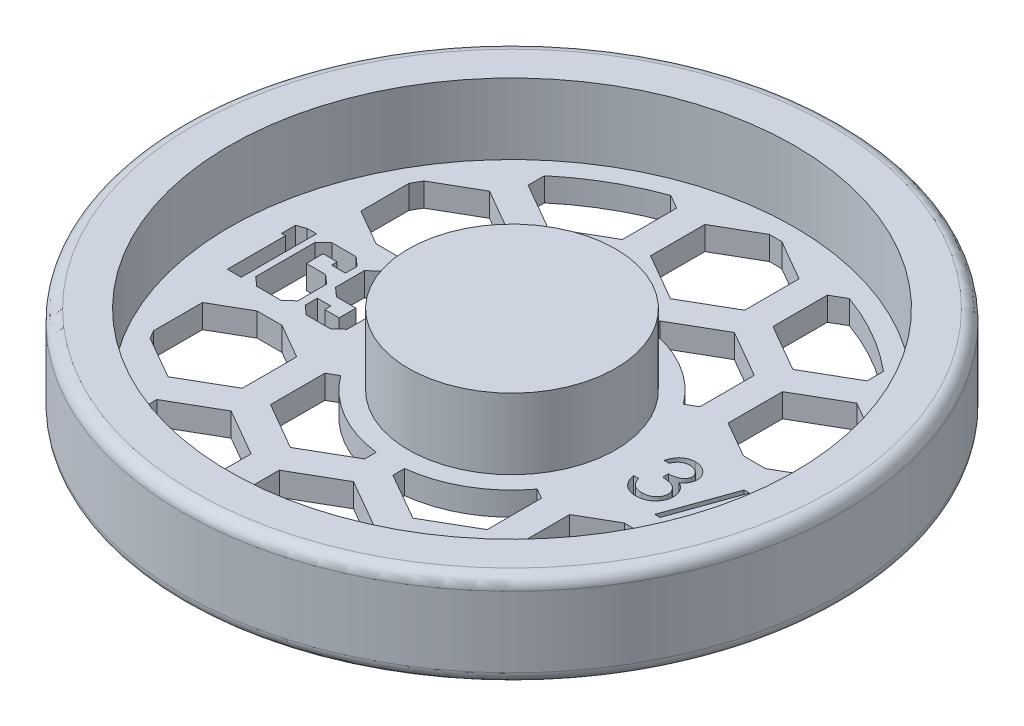
from build123d import *

# Parameters (mm, degrees)
SKETCH2_W               = 1.935420596
SKETCH2_H               = 2.263100716
SKETCH2_W_2             = 1.881765372
CUT_EXTRUDE1_DEPTH      = 64.579325537
CUT_EXTRUDE1_DEPTH_BACK = 64.579325537
CUT_EXTRUDE4_DEPTH      = 64.579325537
CUT_EXTRUDE4_DEPTH_BACK = 64.579325537


with BuildPart() as part:
    # Sketch1 → Revolve1 (revolve)
    with BuildSketch(Plane.XY, mode=Mode.PRIVATE) as revolve1_sk:
        with BuildLine():
            Line((0, 0), (0, 12.7))
            Line((0, 12.7), (13.97, 12.7))
            Line((13.97, 12.7), (13.97, 3.175))
            Line((13.97, 3.175), (38.1, 3.175))
            Line((38.1, 3.175), (38.1, 12.7))
            Line((38.1, 12.7), (42.8625, 12.7))
            ThreePointArc((42.8625, 12.7), (43.985032015, 12.235032015), (44.45, 11.1125))
            Line((44.45, 11.1125), (44.45, 1.5875))
            ThreePointArc((44.45, 1.5875), (43.985032015, 0.464967985), (42.8625, 0))
            Line((42.8625, 0), (0, 0))
        make_face()
    revolve(revolve1_sk.sketch.rotate(Axis((0, 0, 0), (0, 1, 0)), 90), axis=Axis((0, 0, 0), (0, 1, 0)))

    # Sketch2 → Cut-Extrude1 (cut, two sides)
    with BuildSketch(Plane(origin=(0, 3.175, 0), x_dir=(1, 0, 0), z_dir=(0, 1, 0))) as cut_extrude1_sk:
        Polygon((-18.235829876, -4.018393059), (-19.437323651, -5.08), (-22.671967182, -5.08), (-23.875377216, -4.018393059), (-23.875377216, -2.383824972), (-22.045350811, -2.383824972), (-22.045350811, -3.203983402), (-20.109930215, -3.203983402), (-20.109930215, -0.940882686), (-22.729454923, -0.940882686), (-23.927116183, 0.120724255), (-23.927116183, 4.012644285), (-22.729454923, 5.08), (-19.450737458, 5.08), (-18.235829876, 4.006895511), align=None)
        with Locations((-21.077640513, 2.072433044)):
            Rectangle(SKETCH2_W, SKETCH2_H, mode=Mode.SUBTRACT)
        Polygon((-24.883328932, -4.018393059), (-26.086738966, -5.08), (-29.346293851, -5.08), (-30.549703885, -4.018393059), (-30.549703885, 4.012644285), (-29.359707657, 5.08), (-26.105901547, 5.08), (-24.902491513, 4.012644285), (-24.902491513, 2.441312712), (-26.784256884, 2.441312712), (-26.784256884, 3.203983402), (-28.673687288, 3.203983402), (-28.673687288, 0.940882686), (-26.086738966, 0.940882686), (-24.883328932, -0.113059223), align=None)
        with Locations((-27.732804602, -2.072433044)):
            Rectangle(SKETCH2_W_2, SKETCH2_H, mode=Mode.SUBTRACT)
        Polygon((-31.448428895, -5.08), (-33.324445492, -5.08), (-33.324445492, 2.770909091), (-33.860997737, 2.770909091), (-33.860997737, 4.646925688), (-32.703577895, 5.08), (-31.448428895, 5.08), align=None)
        with BuildLine():
            Line((19.147692308, 2.051538462), (18.463846154, 2.051538462))
            add(Edge.make_bspline(
                [(18.463846154, 2.051538462), (18.482372661, 2.128244612), (18.518590468, 2.278198863), (18.594132042, 2.492445528), (18.676426421, 2.695188738), (18.775244986, 2.88263219), (18.883032616, 3.058542943), (19.006526084, 3.218931152), (19.14002788, 3.367875951), (19.287692484, 3.500057342), (19.442549742, 3.619751713), (19.606781685, 3.721805409), (19.7770841, 3.80959685), (19.95463692, 3.881922041), (20.139968757, 3.936406181), (20.331404108, 3.975936141), (20.529444643, 4.001607081), (20.663877969, 4.004112456), (20.732139423, 4.005384615)],
                knots=[0, 0, 0, 0, 1.162005537, 2.271625781, 3.343758855, 4.383309926, 5.390229558, 6.379919256, 7.361854164, 8.333198761, 9.295911338, 10.242430842, 11.177959212, 12.116337295, 13.062827104, 14.020064771, 14.994644689, 16, 16, 16, 16], degree=3))
            add(Edge.make_bspline(
                [(20.732139423, 4.005384615), (20.831597279, 4.002381834), (21.028343525, 3.996441771), (21.317387645, 3.942199484), (21.596120319, 3.856365338), (21.861490625, 3.737768252), (22.107983327, 3.591491873), (22.327300396, 3.417397218), (22.516469097, 3.21884331), (22.67517057, 2.999534127), (22.799430997, 2.765152704), (22.891059044, 2.523924933), (22.946841104, 2.276423041), (22.954070431, 2.109311479), (22.957692308, 2.025588942)],
                knots=[0, 0, 0, 0, 1.083050992, 2.142477498, 3.193116406, 4.255571735, 5.30263384, 6.308962982, 7.297363603, 8.282367274, 9.249857812, 10.179914175, 11.08814088, 12, 12, 12, 12], degree=3))
            add(Edge.make_bspline(
                [(22.957692308, 2.025588942), (22.955159004, 1.945019864), (22.950201721, 1.787358679), (22.908109482, 1.557187877), (22.83727339, 1.340253879), (22.739150078, 1.135643463), (22.612132189, 0.944653954), (22.458267632, 0.766855643), (22.276470408, 0.601459933), (22.13870312, 0.506711824), (22.067776442, 0.457932692)],
                knots=[0, 0, 0, 0, 1.024540389, 2.004866551, 2.965041327, 3.920577974, 4.882998113, 5.874504559, 6.905732034, 8, 8, 8, 8], degree=3))
            add(Edge.make_bspline(
                [(22.067776442, 0.457932692), (22.148835291, 0.418791645), (22.309436314, 0.341241908), (22.528349181, 0.189155945), (22.727074156, 0.013555554), (22.837898824, -0.123479593), (22.893581731, -0.192331731)],
                knots=[0, 0, 0, 0, 1.015518401, 2.012035669, 3.001164323, 4, 4, 4, 4], degree=3))
            add(Edge.make_bspline(
                [(22.893581731, -0.192331731), (22.930247739, -0.24253175), (23.002979324, -0.342109728), (23.092754972, -0.502209033), (23.174199958, -0.664082847), (23.23766415, -0.832069896), (23.286810683, -1.004223143), (23.32194113, -1.180838188), (23.343765117, -1.362059254), (23.346890518, -1.484659568), (23.348461538, -1.546286058)],
                knots=[0, 0, 0, 0, 1.025084078, 2.033381695, 3.024893161, 4.013698104, 4.991890475, 5.976764909, 6.982997093, 8, 8, 8, 8], degree=3))
            add(Edge.make_bspline(
                [(23.348461538, -1.546286058), (23.344554626, -1.652987222), (23.336759188, -1.865887414), (23.267081746, -2.180429522), (23.159066633, -2.487897615), (23.005671818, -2.781974837), (22.818725985, -3.057122981), (22.596314896, -3.303306259), (22.34096563, -3.514921506), (22.056183046, -3.691727774), (21.747644612, -3.833063365), (21.417642894, -3.931159855), (21.070932777, -3.995050288), (20.833172889, -4.001901471), (20.712295673, -4.005384615)],
                knots=[0, 0, 0, 0, 0.955779014, 1.907060117, 2.875433937, 3.871313158, 4.872415639, 5.851225146, 6.836215519, 7.83643374, 8.849228613, 9.86973379, 10.916971861, 12, 12, 12, 12], degree=3))
            add(Edge.make_bspline(
                [(20.712295673, -4.005384615), (20.630828511, -4.003494391), (20.470528301, -3.99977506), (20.234866742, -3.974349077), (20.009920642, -3.927910608), (19.795385861, -3.865419412), (19.59107181, -3.786189391), (19.397601958, -3.687524111), (19.213786019, -3.571457355), (19.041358588, -3.436619087), (18.88034022, -3.285783713), (18.735010004, -3.116273525), (18.602944969, -2.931222035), (18.487681281, -2.728479838), (18.38396883, -2.510667021), (18.29866629, -2.274994576), (18.223586281, -2.023569362), (18.188679138, -1.848357825), (18.170769231, -1.758461538)],
                knots=[0, 0, 0, 0, 1.048658725, 2.063410685, 3.046034179, 4.001477787, 4.936774919, 5.862367409, 6.792675028, 7.730719943, 8.675894397, 9.627829632, 10.600096036, 11.597688215, 12.626045268, 13.701542398, 14.82072376, 16, 16, 16, 16], degree=3))
            Line((18.170769231, -1.758461538), (18.854615385, -1.758461538))
            add(Edge.make_bspline(
                [(18.854615385, -1.758461538), (18.872431579, -1.81713339), (18.907085625, -1.931255238), (18.966073782, -2.095499561), (19.03327842, -2.246066522), (19.105373545, -2.384060634), (19.181091191, -2.510840893), (19.265814542, -2.623054905), (19.353268509, -2.725631431), (19.419190987, -2.783422843), (19.451454327, -2.811706731)],
                knots=[0, 0, 0, 0, 1.198163088, 2.33053128, 3.407730985, 4.417276592, 5.372219308, 6.28897303, 7.162600585, 8, 8, 8, 8], degree=3))
            add(Edge.make_bspline(
                [(19.451454327, -2.811706731), (19.494118874, -2.844599732), (19.579316271, -2.910284201), (19.71814882, -2.994107747), (19.864158658, -3.066739465), (20.020509463, -3.122221111), (20.183827334, -3.169198761), (20.356752055, -3.199941148), (20.537758008, -3.221033681), (20.661349539, -3.222894989), (20.724507212, -3.223846154)],
                knots=[0, 0, 0, 0, 0.946170439, 1.889420265, 2.845303464, 3.807233317, 4.801018734, 5.828864929, 6.890507805, 8, 8, 8, 8], degree=3))
            add(Edge.make_bspline(
                [(20.724507212, -3.223846154), (20.795816266, -3.22250524), (20.935254966, -3.219883199), (21.138719545, -3.195769803), (21.33228376, -3.160651589), (21.513798529, -3.106412466), (21.68564152, -3.039398155), (21.845403854, -2.955255055), (21.995182805, -2.856533119), (22.133059968, -2.744325007), (22.257038473, -2.621487352), (22.366199356, -2.493007466), (22.458999333, -2.35942706), (22.533857295, -2.220006923), (22.592967922, -2.075324396), (22.63320849, -1.924973459), (22.661188074, -1.770184553), (22.663466698, -1.664965484), (22.664615385, -1.611923077)],
                knots=[0, 0, 0, 0, 1.217147791, 2.380027433, 3.494444702, 4.572153297, 5.609568379, 6.639424714, 7.649109417, 8.668170816, 9.669597737, 10.625200337, 11.543417969, 12.441394052, 13.322311151, 14.205496177, 15.095365482, 16, 16, 16, 16], degree=3))
            add(Edge.make_bspline(
                [(22.664615385, -1.611923077), (22.6612837, -1.540923533), (22.654636908, -1.39927773), (22.6038908, -1.190886897), (22.520421616, -0.990103354), (22.403568891, -0.800352748), (22.261323676, -0.624492071), (22.095066365, -0.467582157), (21.903416336, -0.338107273), (21.727024507, -0.248651399), (21.570781509, -0.187610681), (21.437071444, -0.146952615), (21.287378496, -0.112524028), (21.123512902, -0.080493311), (20.944239956, -0.053232547), (20.749754831, -0.030499223), (20.540018116, -0.012309105), (20.394821921, -0.004185977), (20.32, 0)],
                knots=[0, 0, 0, 0, 1.07054697, 2.135767047, 3.216561865, 4.33974944, 5.486079747, 6.621378074, 7.775625952, 8.963672916, 9.598146892, 10.304877434, 11.070270905, 11.915000392, 12.823868403, 13.805723172, 14.86925407, 16, 16, 16, 16], degree=3))
            Line((20.32, 0), (20.32, 0.781538462))
            add(Edge.make_bspline(
                [(20.32, 0.781538462), (20.414272824, 0.783138234), (20.598930127, 0.786271796), (20.868665727, 0.824171521), (21.126599053, 0.876598489), (21.367013845, 0.956902822), (21.586140473, 1.050172268), (21.776247721, 1.15870765), (21.934672195, 1.279353475), (22.060644014, 1.413971899), (22.155413363, 1.558349231), (22.224704848, 1.708826069), (22.265635844, 1.86672131), (22.271099747, 1.974478273), (22.273846154, 2.028641827)],
                knots=[0, 0, 0, 0, 1.321986639, 2.589447074, 3.816329219, 5.01088745, 6.139805852, 7.153945165, 8.075214402, 8.924034688, 9.728124013, 10.488707548, 11.240355623, 12, 12, 12, 12], degree=3))
            add(Edge.make_bspline(
                [(22.273846154, 2.028641827), (22.272943922, 2.068435089), (22.271148974, 2.147601897), (22.248512615, 2.263262761), (22.214496846, 2.375387678), (22.167732407, 2.483499825), (22.105139117, 2.586849392), (22.030232369, 2.686317495), (21.941038963, 2.781336237), (21.838832018, 2.869903104), (21.729078317, 2.954309272), (21.608791664, 3.025966962), (21.481598896, 3.087242783), (21.347359196, 3.137773184), (21.205636928, 3.175784549), (21.057097965, 3.203076866), (20.901459065, 3.22014056), (20.795276037, 3.222597283), (20.741298077, 3.223846154)],
                knots=[0, 0, 0, 0, 0.884392785, 1.759457502, 2.611959086, 3.489218968, 4.37281399, 5.2945488, 6.255912374, 7.266815255, 8.301784654, 9.332968512, 10.37626691, 11.440494194, 12.520033166, 13.637162961, 14.798855837, 16, 16, 16, 16], degree=3))
            add(Edge.make_bspline(
                [(20.741298077, 3.223846154), (20.654535303, 3.22081696), (20.485067425, 3.21490024), (20.24075952, 3.163077679), (20.013641427, 3.080393966), (19.840038959, 2.981697507), (19.711843183, 2.884269419), (19.620235678, 2.799181481), (19.530275023, 2.704622019), (19.447879578, 2.594766928), (19.364551664, 2.477055802), (19.288690075, 2.345504815), (19.214972688, 2.203545534), (19.170553423, 2.103188752), (19.147692308, 2.051538462)],
                knots=[0, 0, 0, 0, 1.472543308, 2.876219568, 4.221790263, 5.565193594, 6.249813518, 6.953379497, 7.687249741, 8.463570142, 9.283606569, 10.136032583, 11.040678096, 12, 12, 12, 12], degree=3))
        make_face()
        Polygon((28.037692308, 4.005384615), (24.850480769, -4.884615385), (24.13, -4.884615385), (27.317211538, 4.005384615), align=None)
        with BuildLine():
            add(Edge.make_bspline(
                [(32.328521635, 0.435036058), (32.390893614, 0.402513994), (32.512539805, 0.339085107), (32.685790756, 0.236953534), (32.844123473, 0.12931349), (32.991930924, 0.021249134), (33.126616277, -0.091378062), (33.246673541, -0.209015962), (33.355068302, -0.32872822), (33.449614615, -0.452541986), (33.532774585, -0.580128325), (33.604646719, -0.711822114), (33.666079601, -0.847334743), (33.714766913, -0.988145442), (33.754873786, -1.132185783), (33.782470389, -1.281315675), (33.797311792, -1.43455244), (33.800117723, -1.538115428), (33.801538462, -1.590552885)],
                knots=[0, 0, 0, 0, 1.272397273, 2.481599622, 3.635517121, 4.734568067, 5.792894095, 6.808321871, 7.773003508, 8.711915296, 9.623354172, 10.525449501, 11.423591555, 12.311487226, 13.218079475, 14.126165749, 15.051214107, 16, 16, 16, 16], degree=3))
            add(Edge.make_bspline(
                [(33.801538462, -1.590552885), (33.799858969, -1.663917663), (33.796534623, -1.809134086), (33.767578657, -2.023465334), (33.724225258, -2.231625842), (33.660915006, -2.433569974), (33.578807567, -2.628183409), (33.477620855, -2.815632739), (33.363078746, -2.998990206), (33.271089585, -3.111808446), (33.224543269, -3.168894231)],
                knots=[0, 0, 0, 0, 1.025265484, 2.029385089, 3.018602448, 3.995076438, 4.983346944, 5.966715145, 6.97116228, 8, 8, 8, 8], degree=3))
            add(Edge.make_bspline(
                [(33.224543269, -3.168894231), (33.163939288, -3.235501248), (33.043480226, -3.3678922), (32.837124252, -3.539779392), (32.610653751, -3.684231502), (32.364945038, -3.801953741), (32.100654914, -3.893580668), (31.817839693, -3.95942295), (31.515948023, -3.997136353), (31.308454397, -4.002587896), (31.202007212, -4.005384615)],
                knots=[0, 0, 0, 0, 0.954267603, 1.896743057, 2.838368354, 3.796610408, 4.779680527, 5.799409237, 6.871065594, 8, 8, 8, 8], degree=3))
            add(Edge.make_bspline(
                [(31.202007212, -4.005384615), (31.099652348, -4.002875506), (30.900480181, -3.997993035), (30.610576459, -3.964912587), (30.340342804, -3.906939917), (30.088207959, -3.827594796), (29.855691946, -3.724375956), (29.643457309, -3.59590622), (29.448441975, -3.447356623), (29.276564224, -3.27446083), (29.123971669, -3.089277691), (28.989929222, -2.898229901), (28.878515943, -2.701300019), (28.784186667, -2.501424443), (28.711975143, -2.295801673), (28.661961359, -2.085489644), (28.630198338, -1.870855705), (28.62597221, -1.726006791), (28.623846154, -1.653137019)],
                knots=[0, 0, 0, 0, 1.256902934, 2.445805442, 3.576955095, 4.645999104, 5.686449165, 6.692658513, 7.68621702, 8.689161843, 9.678783111, 10.630372946, 11.551080876, 12.453998257, 13.34127905, 14.221779781, 15.105423033, 16, 16, 16, 16], degree=3))
            add(Edge.make_bspline(
                [(28.623846154, -1.653137019), (28.625104283, -1.59966815), (28.627590791, -1.493994791), (28.644800775, -1.337873339), (28.672468911, -1.185917183), (28.710045214, -1.03756505), (28.76097082, -0.893896976), (28.822457979, -0.754232231), (28.894155544, -0.618413135), (28.97706368, -0.485696943), (29.073515516, -0.357943262), (29.182728947, -0.232983982), (29.306886764, -0.112758089), (29.444607724, 0.004203305), (29.59431795, 0.119974997), (29.75990606, 0.228300326), (29.93698238, 0.336848238), (30.062833006, 0.40174522), (30.127391827, 0.435036058)],
                knots=[0, 0, 0, 0, 0.941657376, 1.861047343, 2.762797495, 3.66048619, 4.553285746, 5.444104102, 6.34607688, 7.256116206, 8.197091036, 9.162375105, 10.176350973, 11.237807142, 12.343728897, 13.50695164, 14.721116704, 16, 16, 16, 16], degree=3))
            add(Edge.make_bspline(
                [(30.127391827, 0.435036058), (30.039018605, 0.483226611), (29.867903313, 0.576537011), (29.641329273, 0.747980057), (29.446713115, 0.933663814), (29.289404273, 1.137509253), (29.165585308, 1.353148448), (29.080636232, 1.57923222), (29.023167315, 1.811568445), (29.017474463, 1.97029565), (29.014615385, 2.050012019)],
                knots=[0, 0, 0, 0, 1.166880483, 2.259407225, 3.286803203, 4.280235371, 5.237608625, 6.161067461, 7.076446754, 8, 8, 8, 8], degree=3))
            add(Edge.make_bspline(
                [(29.014615385, 2.050012019), (29.018175937, 2.131214132), (29.025333267, 2.29444454), (29.083208953, 2.537427014), (29.177522927, 2.776077936), (29.305802354, 3.009240602), (29.465576808, 3.229023641), (29.657266716, 3.426144215), (29.876294465, 3.598816643), (30.121566736, 3.743762482), (30.38551534, 3.861728048), (30.664006145, 3.943106214), (30.95218691, 3.996307131), (31.148342516, 4.002330533), (31.247800481, 4.005384615)],
                knots=[0, 0, 0, 0, 0.888701115, 1.786444228, 2.72001202, 3.692817113, 4.693886446, 5.687152267, 6.695133018, 7.739871481, 8.800368666, 9.853104506, 10.91144658, 12, 12, 12, 12], degree=3))
            add(Edge.make_bspline(
                [(31.247800481, 4.005384615), (31.344691644, 4.00223572), (31.535749979, 3.996026456), (31.816589711, 3.944239025), (32.085303301, 3.857742185), (32.340964096, 3.74040023), (32.57899519, 3.595866376), (32.789312218, 3.420822187), (32.975093439, 3.224571154), (33.128765749, 3.00485476), (33.255394668, 2.77258803), (33.343570916, 2.529569856), (33.400072071, 2.281051048), (33.407198652, 2.11289288), (33.410769231, 2.028641827)],
                knots=[0, 0, 0, 0, 1.072916533, 2.115669174, 3.151510826, 4.193348718, 5.225979165, 6.227137561, 7.216255879, 8.211077061, 9.189680878, 10.138522389, 11.067357538, 12, 12, 12, 12], degree=3))
            add(Edge.make_bspline(
                [(33.410769231, 2.028641827), (33.407645987, 1.945961204), (33.401512115, 1.783581161), (33.349913961, 1.546867994), (33.263016975, 1.325186869), (33.144375397, 1.116022328), (32.989742765, 0.923167753), (32.80118318, 0.744170753), (32.580199962, 0.577560915), (32.414169118, 0.48353803), (32.328521635, 0.435036058)],
                knots=[0, 0, 0, 0, 0.975232327, 1.915300861, 2.843280834, 3.77672583, 4.742871857, 5.749627742, 6.839139064, 8, 8, 8, 8], degree=3))
        make_face()
        with BuildLine():
            add(Edge.make_bspline(
                [(31.209639423, 3.223846154), (31.156188811, 3.222427875), (31.051616044, 3.219653101), (30.898282765, 3.205156297), (30.752474354, 3.176955293), (30.612667383, 3.139424155), (30.480778654, 3.088722878), (30.355016967, 3.02908003), (30.237522685, 2.956567967), (30.126877448, 2.875227302), (30.027271476, 2.785762175), (29.938869567, 2.692550593), (29.865438644, 2.593761882), (29.803082857, 2.491853396), (29.757838525, 2.383800542), (29.723952812, 2.272916095), (29.701046239, 2.15779883), (29.699329802, 2.079124484), (29.698461538, 2.039326923)],
                knots=[0, 0, 0, 0, 1.203892937, 2.355340988, 3.463153438, 4.544400666, 5.610487187, 6.640501085, 7.674077295, 8.714426146, 9.728707835, 10.68524104, 11.601827946, 12.495867327, 13.368432065, 14.231010473, 15.105153427, 16, 16, 16, 16], degree=3))
            add(Edge.make_bspline(
                [(29.698461538, 2.039326923), (29.699958034, 1.999527642), (29.702915325, 1.920878546), (29.72578649, 1.804736975), (29.759873699, 1.690607583), (29.813541711, 1.581204171), (29.877911897, 1.4727316), (29.957359053, 1.367900896), (30.05204088, 1.26634723), (30.158780621, 1.168934366), (30.275065169, 1.077714773), (30.398256715, 0.998525161), (30.526809144, 0.932265755), (30.659401649, 0.877120022), (30.797385583, 0.834252216), (30.939915448, 0.803840477), (31.087015199, 0.784938529), (31.186686063, 0.782680786), (31.237115385, 0.781538462)],
                knots=[0, 0, 0, 0, 0.873023192, 1.725219244, 2.590779336, 3.480155217, 4.391973325, 5.357036234, 6.360879153, 7.436073238, 8.526419356, 9.601555421, 10.645666583, 11.697338044, 12.750135903, 13.812665442, 14.89329948, 16, 16, 16, 16], degree=3))
            add(Edge.make_bspline(
                [(31.237115385, 0.781538462), (31.301885611, 0.783438818), (31.430786331, 0.787220761), (31.620805904, 0.822384174), (31.805564004, 0.877696486), (31.983085848, 0.953373898), (32.148776402, 1.048357982), (32.296473922, 1.162076724), (32.424918586, 1.291904319), (32.532775571, 1.435819635), (32.616399294, 1.588985093), (32.681499801, 1.742692016), (32.719515362, 1.898580302), (32.72447395, 2.003011235), (32.726923077, 2.054591346)],
                knots=[0, 0, 0, 0, 1.076279235, 2.141928126, 3.20205304, 4.278698113, 5.344010996, 6.36967002, 7.368914609, 8.37248503, 9.349703398, 10.264243087, 11.142681841, 12, 12, 12, 12], degree=3))
            add(Edge.make_bspline(
                [(32.726923077, 2.054591346), (32.72576506, 2.090792956), (32.723466562, 2.162647962), (32.704525297, 2.268758346), (32.673227055, 2.372454754), (32.63085315, 2.474593823), (32.575096968, 2.573742502), (32.508989794, 2.671459397), (32.428686965, 2.765546288), (32.338561016, 2.858195797), (32.236354155, 2.943940443), (32.122263351, 3.019345155), (31.996873529, 3.083380057), (31.860181724, 3.135389288), (31.712691346, 3.174452347), (31.555081717, 3.203705195), (31.386038664, 3.220192941), (31.269714463, 3.222602005), (31.209639423, 3.223846154)],
                knots=[0, 0, 0, 0, 0.814439003, 1.616544685, 2.417341072, 3.248991801, 4.09997495, 4.973547432, 5.9003056, 6.880240646, 7.880314356, 8.896779544, 9.951930927, 11.043077905, 12.18215768, 13.381699519, 14.647792085, 16, 16, 16, 16], degree=3))
        make_face(mode=Mode.SUBTRACT)
        with BuildLine():
            add(Edge.make_bspline(
                [(31.25390625, 0), (31.186140968, -0.001205356), (31.053202021, -0.003569971), (30.858441508, -0.029890541), (30.671526902, -0.066530534), (30.493088412, -0.122114816), (30.32320139, -0.194388318), (30.160946155, -0.281331516), (30.007563982, -0.38410451), (29.865172903, -0.501401599), (29.735146683, -0.627805324), (29.621068099, -0.761617173), (29.52419064, -0.90035023), (29.446176534, -1.045766455), (29.382142991, -1.194786682), (29.340093921, -1.351122075), (29.313137166, -1.511767161), (29.30951738, -1.620972861), (29.307692308, -1.676033654)],
                knots=[0, 0, 0, 0, 1.140299081, 2.23698856, 3.303958914, 4.344563908, 5.37730929, 6.408454204, 7.439741482, 8.480804886, 9.510774543, 10.48932336, 11.43758569, 12.353841022, 13.263987381, 14.161954604, 15.073269652, 16, 16, 16, 16], degree=3))
            add(Edge.make_bspline(
                [(29.307692308, -1.676033654), (29.310660317, -1.744463227), (29.316548778, -1.8802259), (29.363262945, -2.080878072), (29.438234026, -2.275125055), (29.542791781, -2.461383877), (29.672261182, -2.63544668), (29.83146795, -2.7871691), (30.010518002, -2.921981005), (30.215469559, -3.031013481), (30.439341819, -3.118087994), (30.68207524, -3.178081261), (30.940186235, -3.217795504), (31.118406261, -3.221797486), (31.209639423, -3.223846154)],
                knots=[0, 0, 0, 0, 0.898778495, 1.783155532, 2.693654817, 3.627872908, 4.583023416, 5.533784346, 6.509005473, 7.520592997, 8.575161974, 9.658835044, 10.801527049, 12, 12, 12, 12], degree=3))
            add(Edge.make_bspline(
                [(31.209639423, -3.223846154), (31.280941653, -3.222477148), (31.419861261, -3.219809886), (31.62252267, -3.196265622), (31.813772801, -3.158928439), (31.993240779, -3.104622777), (32.162935653, -3.038328828), (32.31998027, -2.95304561), (32.468414663, -2.856048838), (32.600924553, -2.74096908), (32.721610568, -2.618005152), (32.82683905, -2.487833687), (32.918186633, -2.353992453), (32.989882028, -2.213456826), (33.047198044, -2.068923029), (33.088397326, -1.919058288), (33.113818114, -1.763402952), (33.116389093, -1.657813546), (33.117692308, -1.604290865)],
                knots=[0, 0, 0, 0, 1.224942928, 2.386581632, 3.501229538, 4.569074225, 5.605009692, 6.626002462, 7.634866581, 8.645888296, 9.63523824, 10.59253846, 11.518950513, 12.414518923, 13.29783783, 14.186679152, 15.080837789, 16, 16, 16, 16], degree=3))
            add(Edge.make_bspline(
                [(33.117692308, -1.604290865), (33.115720146, -1.552306484), (33.111831388, -1.449802364), (33.087149791, -1.297910669), (33.043790081, -1.151165114), (32.984294435, -1.007800244), (32.905087882, -0.870720905), (32.811808479, -0.736355984), (32.699262998, -0.60843481), (32.572090431, -0.485963784), (32.43349578, -0.372718094), (32.286174739, -0.272538088), (32.13126131, -0.188169195), (31.969083302, -0.119553282), (31.800000823, -0.065587419), (31.624138237, -0.027888024), (31.441289642, -0.004158032), (31.317073038, -0.001401669), (31.25390625, 0)],
                knots=[0, 0, 0, 0, 0.917430815, 1.809013306, 2.70690318, 3.612392954, 4.541220862, 5.495268465, 6.494511384, 7.542276156, 8.608045339, 9.649016899, 10.681629292, 11.715607085, 12.752076957, 13.808767841, 14.885711793, 16, 16, 16, 16], degree=3))
        make_face(mode=Mode.SUBTRACT)
    extrude(amount=CUT_EXTRUDE1_DEPTH, mode=Mode.SUBTRACT)
    extrude(cut_extrude1_sk.sketch, amount=-CUT_EXTRUDE1_DEPTH_BACK, mode=Mode.SUBTRACT)


with BuildPart() as cut_extrude1_kept_piece:
    # of the separate pieces the step leaves, the one the design keeps (cut_extrude1_pieces_kept)
    add(part.part.solids().sort_by_distance((0, 0, -42.8625))[0])

    # Sketch3 → Cut-Extrude4 (cut, two sides)
    with BuildSketch(Plane(origin=(0, 3.175, 0), x_dir=(1, 0, 0), z_dir=(0, 1, 0))) as cut_extrude4_sk:
        with BuildLine():
            ThreePointArc((-1.905, -16.399727894), (-8.255, -14.298079416), (-13.250080971, -9.849642341))
            Line((-13.250080971, -9.849642341), (-14.605, -10.631905207))
            Line((-14.605, -10.631905207), (-14.605, -17.964253626))
            Line((-14.605, -17.964253626), (-8.255, -21.630427835))
            Line((-8.255, -21.630427835), (-1.905, -17.964253626))
            Line((-1.905, -17.964253626), (-1.905, -16.399727894))
        make_face()
        with BuildLine():
            Line((14.605, -10.631905207), (13.250080971, -9.849642341))
            ThreePointArc((13.250080971, -9.849642341), (8.255, -14.298079416), (1.905, -16.399727894))
            Line((1.905, -16.399727894), (1.905, -17.964253626))
            Line((1.905, -17.964253626), (8.255, -21.630427835))
            Line((8.255, -21.630427835), (14.605, -17.964253626))
            Line((14.605, -17.964253626), (14.605, -10.631905207))
        make_face()
        with BuildLine():
            Line((-18.415, -10.631905207), (-23.081846715, -7.9375))
            Line((-23.081846715, -7.9375), (-26.448153285, -7.9375))
            Line((-26.448153285, -7.9375), (-31.115, -10.631905207))
            Line((-31.115, -10.631905207), (-31.115, -17.215410974))
            ThreePointArc((-31.115, -17.215410974), (-30.795863359, -17.78), (-30.46648324, -18.338674952))
            Line((-30.46648324, -18.338674952), (-24.765, -21.630427835))
            Line((-24.765, -21.630427835), (-18.415, -17.964253626))
            Line((-18.415, -17.964253626), (-18.415, -10.631905207))
        make_face()
        with BuildLine():
            Line((26.448153285, -7.9375), (23.081846715, -7.9375))
            Line((23.081846715, -7.9375), (18.415, -10.631905207))
            Line((18.415, -10.631905207), (18.415, -17.964253626))
            Line((18.415, -17.964253626), (24.765, -21.630427835))
            Line((24.765, -21.630427835), (30.46648324, -18.338674952))
            ThreePointArc((30.46648324, -18.338674952), (30.795863359, -17.78), (31.115, -17.215410974))
            Line((31.115, -17.215410974), (31.115, -10.631905207))
            Line((31.115, -10.631905207), (26.448153285, -7.9375))
        make_face()
        with BuildLine():
            Line((-14.605, 10.737746374), (-13.194804504, 9.923569625))
            ThreePointArc((-13.194804504, 9.923569625), (-8.214997291, 14.321100499), (-1.905, 16.399727894))
            Line((-1.905, 16.399727894), (-1.905, 18.070094793))
            Line((-1.905, 18.070094793), (-8.255, 21.736269002))
            Line((-8.255, 21.736269002), (-14.605, 18.070094793))
            Line((-14.605, 18.070094793), (-14.605, 10.737746374))
        make_face()
        with BuildLine():
            ThreePointArc((1.905, 16.399727894), (8.214997291, 14.321100499), (13.194804504, 9.923569625))
            Line((13.194804504, 9.923569625), (14.605, 10.737746374))
            Line((14.605, 10.737746374), (14.605, 18.070094793))
            Line((14.605, 18.070094793), (8.255, 21.736269002))
            Line((8.255, 21.736269002), (1.905, 18.070094793))
            Line((1.905, 18.070094793), (1.905, 16.399727894))
        make_face()
        with BuildLine():
            Line((-26.264831006, 7.9375), (-23.265168994, 7.9375))
            Line((-23.265168994, 7.9375), (-18.415, 10.737746374))
            Line((-18.415, 10.737746374), (-18.415, 18.070094793))
            Line((-18.415, 18.070094793), (-24.765, 21.736269002))
            Line((-24.765, 21.736269002), (-30.367930984, 18.50141529))
            ThreePointArc((-30.367930984, 18.50141529), (-30.748189416, 17.862319212), (-31.115, 17.215410974))
            Line((-31.115, 17.215410974), (-31.115, 10.737746374))
            Line((-31.115, 10.737746374), (-26.264831006, 7.9375))
        make_face()
        with BuildLine():
            Line((18.415, 10.737746374), (23.265168994, 7.9375))
            Line((23.265168994, 7.9375), (26.264831006, 7.9375))
            Line((26.264831006, 7.9375), (31.115, 10.737746374))
            Line((31.115, 10.737746374), (31.115, 17.215410974))
            ThreePointArc((31.115, 17.215410974), (30.748189416, 17.862319212), (30.367930984, 18.50141529))
            Line((30.367930984, 18.50141529), (24.765, 21.736269002))
            Line((24.765, 21.736269002), (18.415, 18.070094793))
            Line((18.415, 18.070094793), (18.415, 10.737746374))
        make_face()
        with BuildLine():
            Line((-22.86, -25.035825791), (-22.86, -27.238465449))
            ThreePointArc((-22.86, -27.238465449), (-17.728085176, -30.825778108), (-12.046523441, -33.457359026))
            Line((-12.046523441, -33.457359026), (-10.16, -32.368174209))
            Line((-10.16, -32.368174209), (-10.16, -25.035825791))
            Line((-10.16, -25.035825791), (-16.51, -21.369651581))
            Line((-16.51, -21.369651581), (-22.86, -25.035825791))
        make_face()
        with BuildLine():
            ThreePointArc((12.046523441, -33.457359026), (17.728085176, -30.825778108), (22.86, -27.238465449))
            Line((22.86, -27.238465449), (22.86, -25.035825791))
            Line((22.86, -25.035825791), (16.51, -21.369651581))
            Line((16.51, -21.369651581), (10.16, -25.035825791))
            Line((10.16, -25.035825791), (10.16, -32.368174209))
            Line((10.16, -32.368174209), (12.046523441, -33.457359026))
        make_face()
        with BuildLine():
            Line((-6.35, -32.368174209), (-0.838730155, -35.550107338))
            ThreePointArc((-0.838730155, -35.550107338), (0, -35.56), (0.838730155, -35.550107338))
            Line((0.838730155, -35.550107338), (6.35, -32.368174209))
            Line((6.35, -32.368174209), (6.35, -25.035825791))
            Line((6.35, -25.035825791), (0, -21.369651581))
            Line((0, -21.369651581), (-6.35, -25.035825791))
            Line((-6.35, -25.035825791), (-6.35, -32.368174209))
        make_face()
        with BuildLine():
            ThreePointArc((-12.046523441, 33.457359026), (-17.728085176, 30.825778108), (-22.86, 27.238465449))
            Line((-22.86, 27.238465449), (-22.86, 25.035825791))
            Line((-22.86, 25.035825791), (-16.51, 21.369651581))
            Line((-16.51, 21.369651581), (-10.16, 25.035825791))
            Line((-10.16, 25.035825791), (-10.16, 32.368174209))
            Line((-10.16, 32.368174209), (-12.046523441, 33.457359026))
        make_face()
        with BuildLine():
            Line((22.86, 25.035825791), (22.86, 27.238465449))
            ThreePointArc((22.86, 27.238465449), (17.728085176, 30.825778108), (12.046523441, 33.457359026))
            Line((12.046523441, 33.457359026), (10.16, 32.368174209))
            Line((10.16, 32.368174209), (10.16, 25.035825791))
            Line((10.16, 25.035825791), (16.51, 21.369651581))
            Line((16.51, 21.369651581), (22.86, 25.035825791))
        make_face()
        with BuildLine():
            ThreePointArc((0.838730155, 35.550107338), (0, 35.56), (-0.838730155, 35.550107338))
            Line((-0.838730155, 35.550107338), (-6.35, 32.368174209))
            Line((-6.35, 32.368174209), (-6.35, 25.035825791))
            Line((-6.35, 25.035825791), (0, 21.369651581))
            Line((0, 21.369651581), (6.35, 25.035825791))
            Line((6.35, 25.035825791), (6.35, 32.368174209))
            Line((6.35, 32.368174209), (0.838730155, 35.550107338))
        make_face()
    extrude(amount=CUT_EXTRUDE4_DEPTH, mode=Mode.SUBTRACT)
    extrude(cut_extrude4_sk.sketch, amount=-CUT_EXTRUDE4_DEPTH_BACK, mode=Mode.SUBTRACT)


solid = cut_extrude1_kept_piece.part
